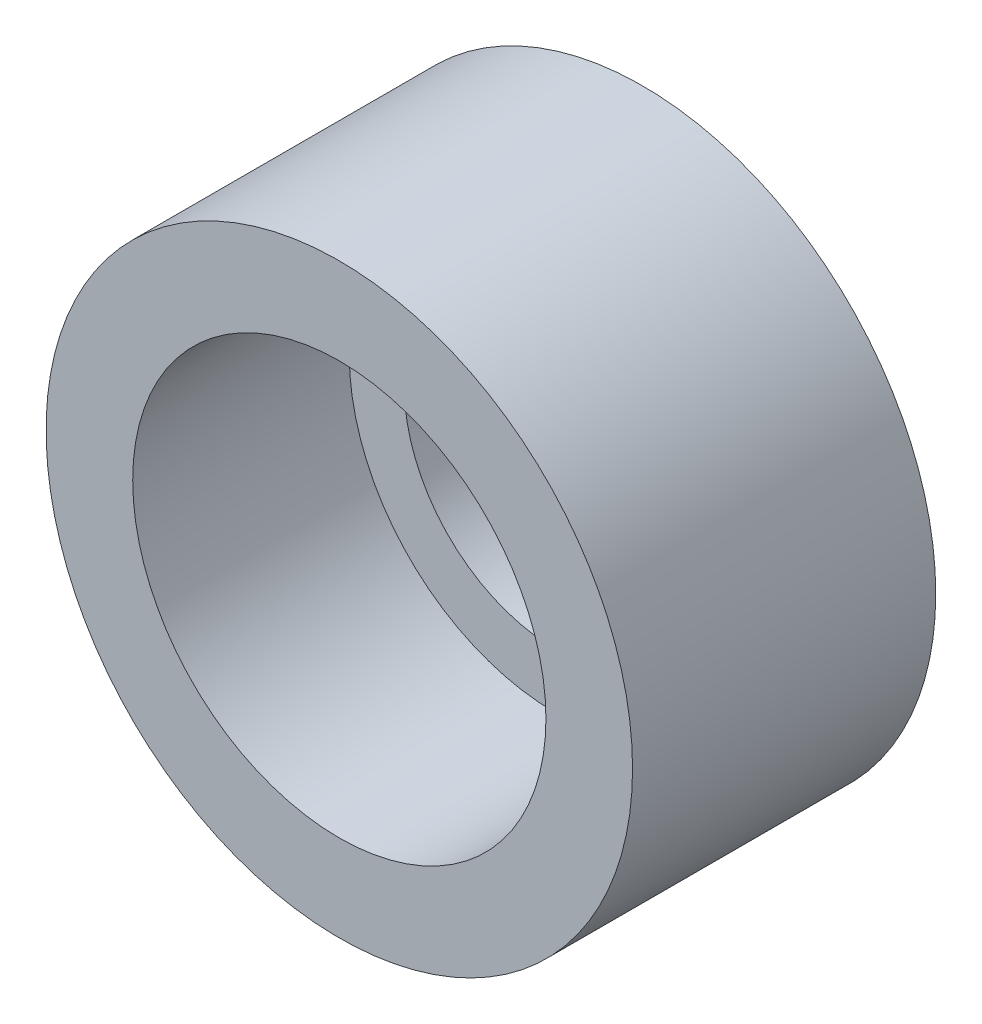
from build123d import *

# Parameters (mm, degrees)
SKETCH1_R           = 8.598499948
SKETCH1_R_2         = 6.058499948
BOSS_EXTRUDE1_DEPTH = 6.35
SKETCH2_R           = 8.598499948
BOSS_EXTRUDE2_DEPTH = 2.54
SKETCH3_R           = 4.445
CUT_EXTRUDE1_DEPTH  = 9.89


with BuildPart() as part:
    # Sketch1 → Boss-Extrude1 (new body)
    with BuildSketch(Plane.XY):
        Circle(SKETCH1_R)
        Circle(SKETCH1_R_2, mode=Mode.SUBTRACT)
    extrude(amount=BOSS_EXTRUDE1_DEPTH)

    # Sketch2 → Boss-Extrude2 (add)
    with BuildSketch(Plane.XY):
        Circle(SKETCH2_R)
    extrude(amount=-BOSS_EXTRUDE2_DEPTH)

    # Sketch3 → Cut-Extrude1 (cut, through all)
    with BuildSketch(Plane(origin=(0, 0, -2.54), x_dir=(-1, 0, 0), z_dir=(0, 0, -1))):
        Circle(SKETCH3_R)
    extrude(amount=-CUT_EXTRUDE1_DEPTH, mode=Mode.SUBTRACT)


solid = part.part
